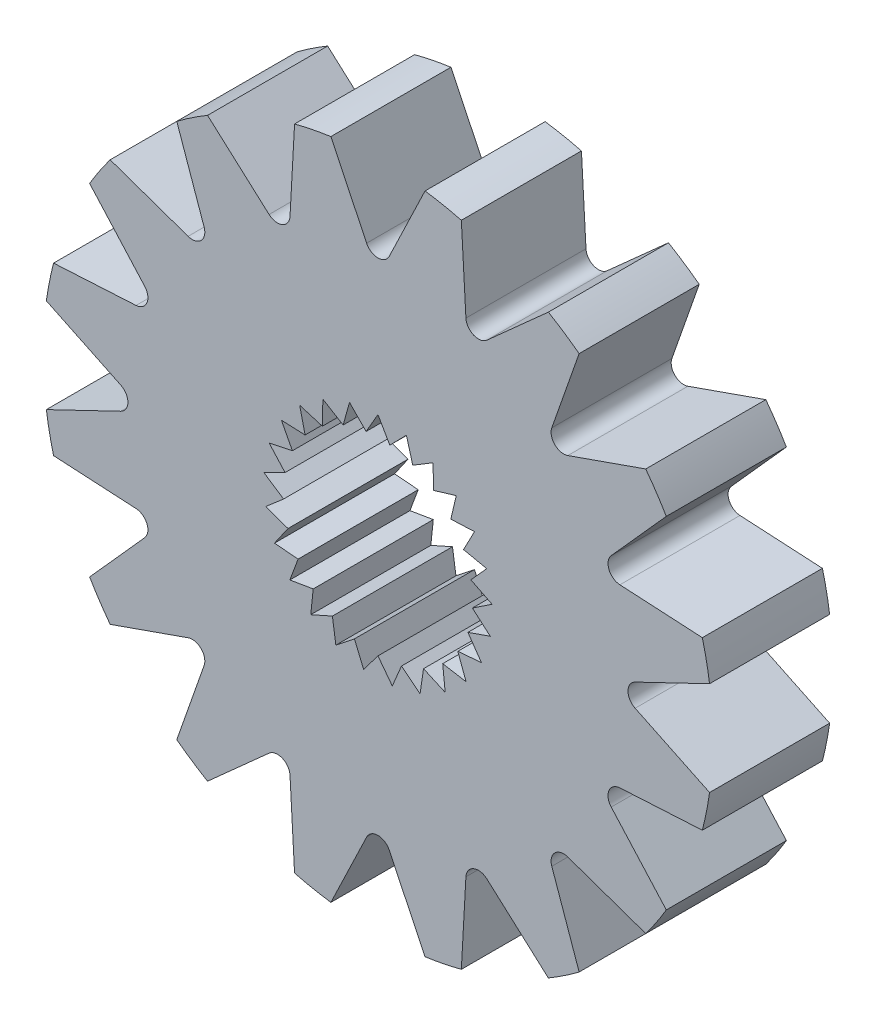
from build123d import *

# Parameters (mm, degrees)
SKETCH1_R           = 8.926200703
BOSS_EXTRUDE1_DEPTH = 3.2004
CUT_EXTRUDE1_DEPTH  = 3.2004


with BuildPart() as part:
    # Sketch1 → Boss-Extrude1 (new body)
    with BuildSketch(Plane.XY):
        Circle(SKETCH1_R)
        Polygon((0, 3.048), (-0.315924789, 2.500802214), (-0.758006776, 2.952241475), (-0.927923651, 2.343667613), (-1.468385199, 2.670982761), (-1.481617658, 2.039271757), (-2.086499579, 2.221896376), (-1.942216178, 1.606740957), (-2.573511517, 1.633200071), (-2.280778112, 1.073252713), (-2.898820262, 0.941883799), (-2.47603037, 0.472328054), (-3.041985468, 0.191385504), (-2.515704533, -0.158274714), (-2.99401154, -0.571138247), (-2.397307729, -0.778932499), (-2.757912856, -1.297775281), (-2.128279263, -1.350647091), (-2.348524364, -1.942868321), (-1.725523184, -1.837495558), (-1.791569449, -2.465883799), (-1.214346137, -2.208887422), (-1.122043637, -2.833958729), (-0.626867256, -2.441486766), (-0.382015696, -3.02396561), (0, -2.520678517), (0.382015696, -3.02396561), (0.626867256, -2.441486766), (1.122043637, -2.833958729), (1.214346137, -2.208887422), (1.791569449, -2.465883799), (1.725523184, -1.837495558), (2.348524364, -1.942868321), (2.128279263, -1.350647091), (2.757912856, -1.297775281), (2.397307729, -0.778932499), (2.99401154, -0.571138247), (2.515704533, -0.158274714), (3.041985468, 0.191385504), (2.47603037, 0.472328054), (2.898820262, 0.941883799), (2.280778112, 1.073252713), (2.573511517, 1.633200071), (1.942216178, 1.606740957), (2.086499579, 2.221896376), (1.481617658, 2.039271757), (1.468385199, 2.670982761), (0.927923651, 2.343667613), (0.758006776, 2.952241475), (0.315924789, 2.500802214), align=None, mode=Mode.SUBTRACT)
    extrude(amount=BOSS_EXTRUDE1_DEPTH)

    # Sketch2 → Cut-Extrude1 (cut)
    with BuildSketch(Plane.XY.offset(3.2004)):
        with BuildLine():
            Line((-1.255122678, 8.837518093), (-0.301897322, 6.853917937))
            ThreePointArc((-0.301897322, 6.853917937), (0, 6.664048588), (0.301897322, 6.853917937))
            Line((0.301897322, 6.853917937), (1.255122678, 8.837518093))
            ThreePointArc((1.255122678, 8.837518093), (0, 8.926200703), (-1.255122678, 8.837518093))
        make_face()
        with BuildLine():
            Line((2.901797598, 6.216663396), (4.54155391, 7.68448743))
            ThreePointArc((4.54155391, 7.68448743), (3.415909123, 8.246734132), (2.222389605, 8.645116739))
            Line((2.222389605, 8.645116739), (2.343964085, 6.447725603))
            ThreePointArc((2.343964085, 6.447725603), (2.550220987, 6.156778094), (2.901797598, 6.216663396))
        make_face()
        with BuildLine():
            Line((5.059925495, 4.632978207), (7.136574729, 5.361563216))
            ThreePointArc((7.136574729, 5.361563216), (6.311777047, 6.311777047), (5.361563216, 7.136574729))
            Line((5.361563216, 7.136574729), (4.632978207, 5.059925495))
            ThreePointArc((4.632978207, 5.059925495), (4.712193947, 4.712193947), (5.059925495, 4.632978207))
        make_face()
        with BuildLine():
            Line((6.447725603, 2.343964085), (8.645116739, 2.222389605))
            ThreePointArc((8.645116739, 2.222389605), (8.246734132, 3.415909123), (7.68448743, 4.54155391))
            Line((7.68448743, 4.54155391), (6.216663396, 2.901797598))
            ThreePointArc((6.216663396, 2.901797598), (6.156778094, 2.550220987), (6.447725603, 2.343964085))
        make_face()
        with BuildLine():
            Line((6.853917937, -0.301897322), (8.837518093, -1.255122678))
            ThreePointArc((8.837518093, -1.255122678), (8.926200703, 0), (8.837518093, 1.255122678))
            Line((8.837518093, 1.255122678), (6.853917937, 0.301897322))
            ThreePointArc((6.853917937, 0.301897322), (6.664048588, 0), (6.853917937, -0.301897322))
        make_face()
        with BuildLine():
            Line((6.216663396, -2.901797598), (7.68448743, -4.54155391))
            ThreePointArc((7.68448743, -4.54155391), (8.246734132, -3.415909123), (8.645116739, -2.222389605))
            Line((8.645116739, -2.222389605), (6.447725603, -2.343964085))
            ThreePointArc((6.447725603, -2.343964085), (6.156778094, -2.550220987), (6.216663396, -2.901797598))
        make_face()
        with BuildLine():
            Line((4.632978207, -5.059925495), (5.361563216, -7.136574729))
            ThreePointArc((5.361563216, -7.136574729), (6.311777047, -6.311777047), (7.136574729, -5.361563216))
            Line((7.136574729, -5.361563216), (5.059925495, -4.632978207))
            ThreePointArc((5.059925495, -4.632978207), (4.712193947, -4.712193947), (4.632978207, -5.059925495))
        make_face()
        with BuildLine():
            Line((2.343964085, -6.447725603), (2.222389605, -8.645116739))
            ThreePointArc((2.222389605, -8.645116739), (3.415909123, -8.246734132), (4.54155391, -7.68448743))
            Line((4.54155391, -7.68448743), (2.901797598, -6.216663396))
            ThreePointArc((2.901797598, -6.216663396), (2.550220987, -6.156778094), (2.343964085, -6.447725603))
        make_face()
        with BuildLine():
            Line((-0.301897322, -6.853917937), (-1.255122678, -8.837518093))
            ThreePointArc((-1.255122678, -8.837518093), (0, -8.926200703), (1.255122678, -8.837518093))
            Line((1.255122678, -8.837518093), (0.301897322, -6.853917937))
            ThreePointArc((0.301897322, -6.853917937), (0, -6.664048588), (-0.301897322, -6.853917937))
        make_face()
        with BuildLine():
            Line((-2.901797598, -6.216663396), (-4.54155391, -7.68448743))
            ThreePointArc((-4.54155391, -7.68448743), (-3.415909123, -8.246734132), (-2.222389605, -8.645116739))
            Line((-2.222389605, -8.645116739), (-2.343964085, -6.447725603))
            ThreePointArc((-2.343964085, -6.447725603), (-2.550220987, -6.156778094), (-2.901797598, -6.216663396))
        make_face()
        with BuildLine():
            Line((-5.059925495, -4.632978207), (-7.136574729, -5.361563216))
            ThreePointArc((-7.136574729, -5.361563216), (-6.311777047, -6.311777047), (-5.361563216, -7.136574729))
            Line((-5.361563216, -7.136574729), (-4.632978207, -5.059925495))
            ThreePointArc((-4.632978207, -5.059925495), (-4.712193947, -4.712193947), (-5.059925495, -4.632978207))
        make_face()
        with BuildLine():
            Line((-6.447725603, -2.343964085), (-8.645116739, -2.222389605))
            ThreePointArc((-8.645116739, -2.222389605), (-8.246734132, -3.415909123), (-7.68448743, -4.54155391))
            Line((-7.68448743, -4.54155391), (-6.216663396, -2.901797598))
            ThreePointArc((-6.216663396, -2.901797598), (-6.156778094, -2.550220987), (-6.447725603, -2.343964085))
        make_face()
        with BuildLine():
            Line((-6.853917937, 0.301897322), (-8.837518093, 1.255122678))
            ThreePointArc((-8.837518093, 1.255122678), (-8.926200703, 0), (-8.837518093, -1.255122678))
            Line((-8.837518093, -1.255122678), (-6.853917937, -0.301897322))
            ThreePointArc((-6.853917937, -0.301897322), (-6.664048588, 0), (-6.853917937, 0.301897322))
        make_face()
        with BuildLine():
            Line((-6.216663396, 2.901797598), (-7.68448743, 4.54155391))
            ThreePointArc((-7.68448743, 4.54155391), (-8.246734132, 3.415909123), (-8.645116739, 2.222389605))
            Line((-8.645116739, 2.222389605), (-6.447725603, 2.343964085))
            ThreePointArc((-6.447725603, 2.343964085), (-6.156778094, 2.550220987), (-6.216663396, 2.901797598))
        make_face()
        with BuildLine():
            Line((-4.632978207, 5.059925495), (-5.361563216, 7.136574729))
            ThreePointArc((-5.361563216, 7.136574729), (-6.311777047, 6.311777047), (-7.136574729, 5.361563216))
            Line((-7.136574729, 5.361563216), (-5.059925495, 4.632978207))
            ThreePointArc((-5.059925495, 4.632978207), (-4.712193947, 4.712193947), (-4.632978207, 5.059925495))
        make_face()
        with BuildLine():
            Line((-2.343964085, 6.447725603), (-2.222389605, 8.645116739))
            ThreePointArc((-2.222389605, 8.645116739), (-3.415909123, 8.246734132), (-4.54155391, 7.68448743))
            Line((-4.54155391, 7.68448743), (-2.901797598, 6.216663396))
            ThreePointArc((-2.901797598, 6.216663396), (-2.550220987, 6.156778094), (-2.343964085, 6.447725603))
        make_face()
    extrude(amount=-CUT_EXTRUDE1_DEPTH, mode=Mode.SUBTRACT)


solid = part.part
